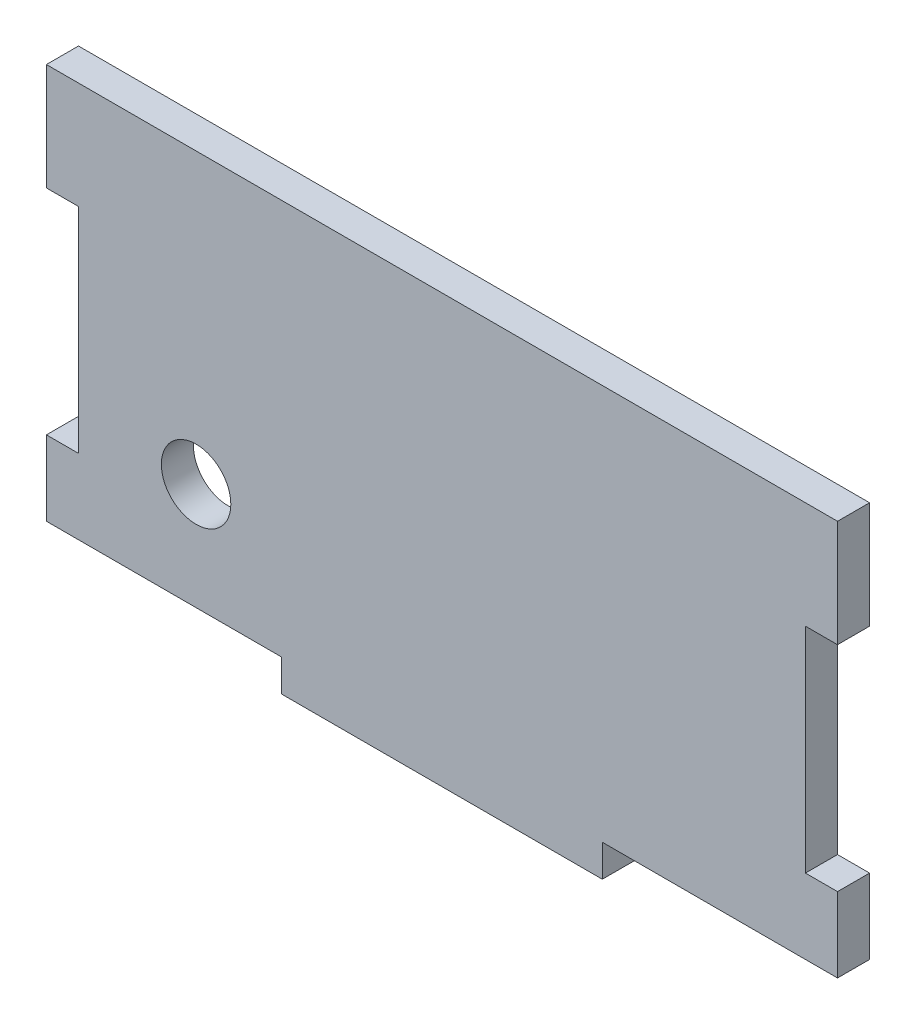
from build123d import *

# Parameters (mm, degrees)
ESBO_O1_W                = 74
ESBO_O1_H                = 40
RESSALTO_EXTRUS_O1_DEPTH = 3
ESBO_O2_W                = 22
ESBO_O2_H                = 3
ESBO_O2_W_2              = 3
ESBO_O2_H_2              = 20
CORTE_EXTRUS_O1_DEPTH    = 3
ESBO_O3_R                = 3.25
CORTE_EXTRUS_O2_DEPTH    = 10


with BuildPart() as part:
    # Esboço1 → Ressalto-extrusão1 (new body)
    with BuildSketch(Plane.XY):
        Rectangle(ESBO_O1_W, ESBO_O1_H)
    extrude(amount=RESSALTO_EXTRUS_O1_DEPTH)

    # Esboço2 → Corte-extrusão1 (cut)
    with BuildSketch(Plane.XY.offset(3)):
        with Locations((-26, -18.5)):
            Rectangle(ESBO_O2_W, ESBO_O2_H)
        with Locations((26, -18.5)):
            Rectangle(ESBO_O2_W, ESBO_O2_H)
        with Locations((-35.5, 0)):
            Rectangle(ESBO_O2_W_2, ESBO_O2_H_2)
        with Locations((35.5, 0)):
            Rectangle(ESBO_O2_W_2, ESBO_O2_H_2)
    extrude(amount=-CORTE_EXTRUS_O1_DEPTH, mode=Mode.SUBTRACT)

    # Esboço3 → Corte-extrusão2 (cut)
    with BuildSketch(Plane.XY.offset(3)):
        with Locations((-23, -7)):
            Circle(ESBO_O3_R)
    extrude(amount=-CORTE_EXTRUS_O2_DEPTH, mode=Mode.SUBTRACT)


solid = part.part
